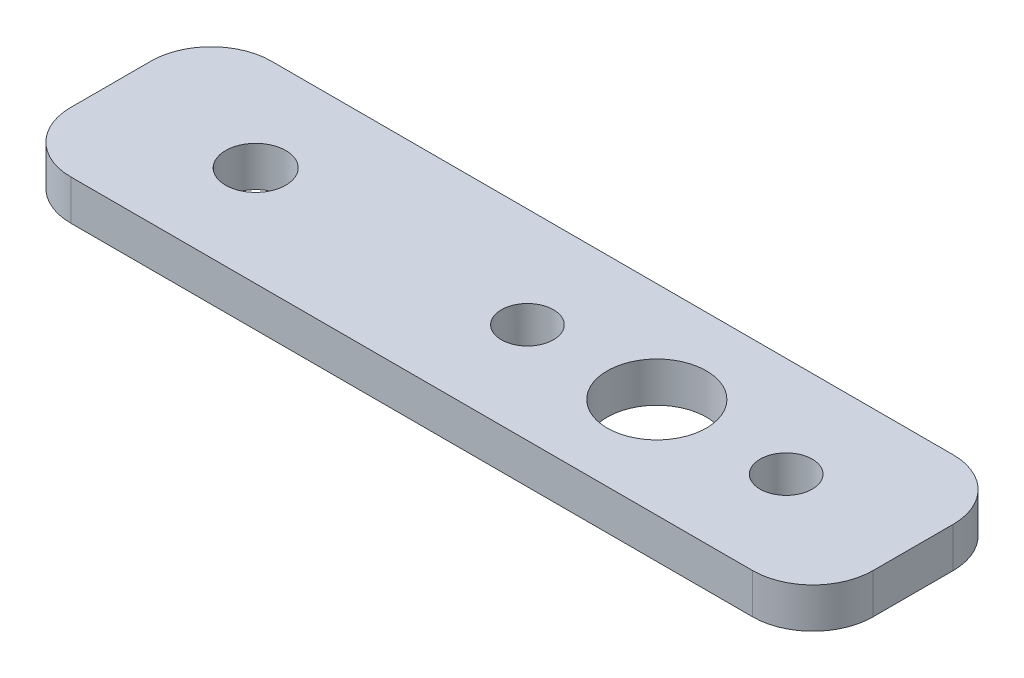
from build123d import *

# Parameters (mm, degrees)
SKETCH1_W                = 40
SKETCH1_H                = 10
BOSS_EXTRUDE1_DEPTH      = 2
SKETCH2_R                = 2.472864358
SKETCH2_R_2              = 1.3
CUT_EXTRUDE1_DEPTH       = 3
FILLET1_R                = 3
F_3_0_3_DIAMETER_HOLE1_D = 3


with BuildPart() as part:
    # Sketch1 → Boss-Extrude1 (new body)
    with BuildSketch(Plane(origin=(0, 0, 0), x_dir=(1, 0, 0), z_dir=(0, 1, 0))):
        Rectangle(SKETCH1_W, SKETCH1_H)
    extrude(amount=BOSS_EXTRUDE1_DEPTH)

    # Sketch2 → Cut-Extrude1 (cut)
    with BuildSketch(Plane(origin=(0, 2, 0), x_dir=(1, 0, 0), z_dir=(0, 1, 0))):
        with Locations((7.219918586, 0)):
            Circle(SKETCH2_R)
        with Locations((13.669918586, 0)):
            Circle(SKETCH2_R_2)
        with Locations((0.769918586, 0)):
            Circle(SKETCH2_R_2)
    extrude(amount=-CUT_EXTRUDE1_DEPTH, mode=Mode.SUBTRACT)

    # Fillet1
    fillet1_edges = [part.edges().sort_by_distance(p)[0] for p in [
        (20, 1, 5),
        (-20, 1, 5),
        (-20, 1, -5),
        (20, 1, -5),
    ]]
    fillet(fillet1_edges, radius=FILLET1_R)

    # Ø3.0 (3) Diameter Hole1 (through all)
    with Locations(Plane(origin=(0, 2, 0), x_dir=(1, 0, 0), z_dir=(0, 1, 0))):
        with Locations((-12.780081414, 0)):
            Hole(F_3_0_3_DIAMETER_HOLE1_D / 2)


solid = part.part
